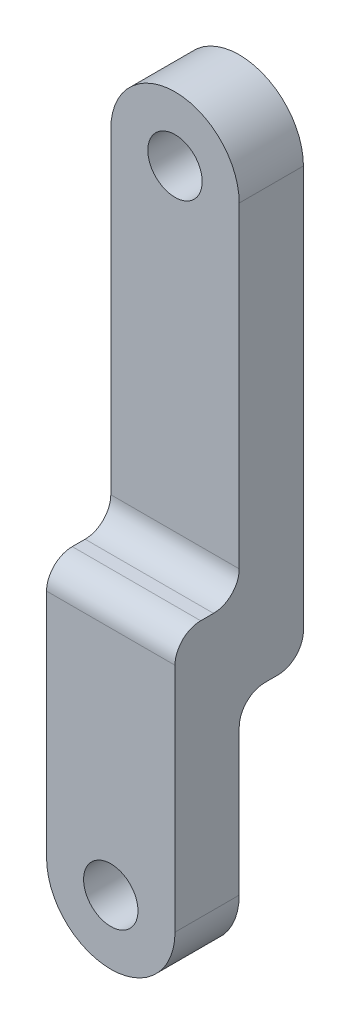
from build123d import *

# Parameters (mm, degrees)
SKETCH1_R           = 3.175
BOSS_EXTRUDE1_DEPTH = 15
CUT_EXTRUDE1_DEPTH  = 7.5
CUT_EXTRUDE2_DEPTH  = 7.5
FILLET1_R           = 3


with BuildPart() as part:
    # Sketch1 → Boss-Extrude1 (new body)
    with BuildSketch(Plane.XY):
        with BuildLine():
            Line((7.5, 70), (7.5, 0))
            ThreePointArc((7.5, 0), (0, -7.5), (-7.5, 0))
            Line((-7.5, 0), (-7.5, 70))
            ThreePointArc((-7.5, 70), (0, 77.5), (7.5, 70))
        make_face()
        with Locations((0, 70)):
            Circle(SKETCH1_R, mode=Mode.SUBTRACT)
        Circle(SKETCH1_R, mode=Mode.SUBTRACT)
    extrude(amount=BOSS_EXTRUDE1_DEPTH)

    # Sketch2 → Cut-Extrude1 (cut)
    with BuildSketch(Plane.XY.offset(15)):
        with BuildLine():
            Line((-7.5, 30), (7.5, 30))
            Line((7.5, 30), (7.5, 70))
            ThreePointArc((7.5, 70), (0, 77.5), (-7.5, 70))
            Line((-7.5, 70), (-7.5, 30))
        make_face()
    extrude(amount=-CUT_EXTRUDE1_DEPTH, mode=Mode.SUBTRACT)

    # Sketch3 → Cut-Extrude2 (cut)
    with BuildSketch(Plane(origin=(0, 0, 0), x_dir=(-1, 0, 0), z_dir=(0, 0, -1))):
        with BuildLine():
            Line((-7.5, 0), (-7.5, 20))
            Line((-7.5, 20), (7.5, 20))
            Line((7.5, 20), (7.5, 0))
            ThreePointArc((7.5, 0), (0, -7.5), (-7.5, 0))
        make_face()
    extrude(amount=-CUT_EXTRUDE2_DEPTH, mode=Mode.SUBTRACT)

    # Fillet1
    fillet1_edges = [part.edges().sort_by_distance(p)[0] for p in [
        (0, 30, 7.5),
        (0, 30, 15),
        (0, 20, 7.5),
        (0, 20, 0),
    ]]
    fillet(fillet1_edges, radius=FILLET1_R)


solid = part.part
